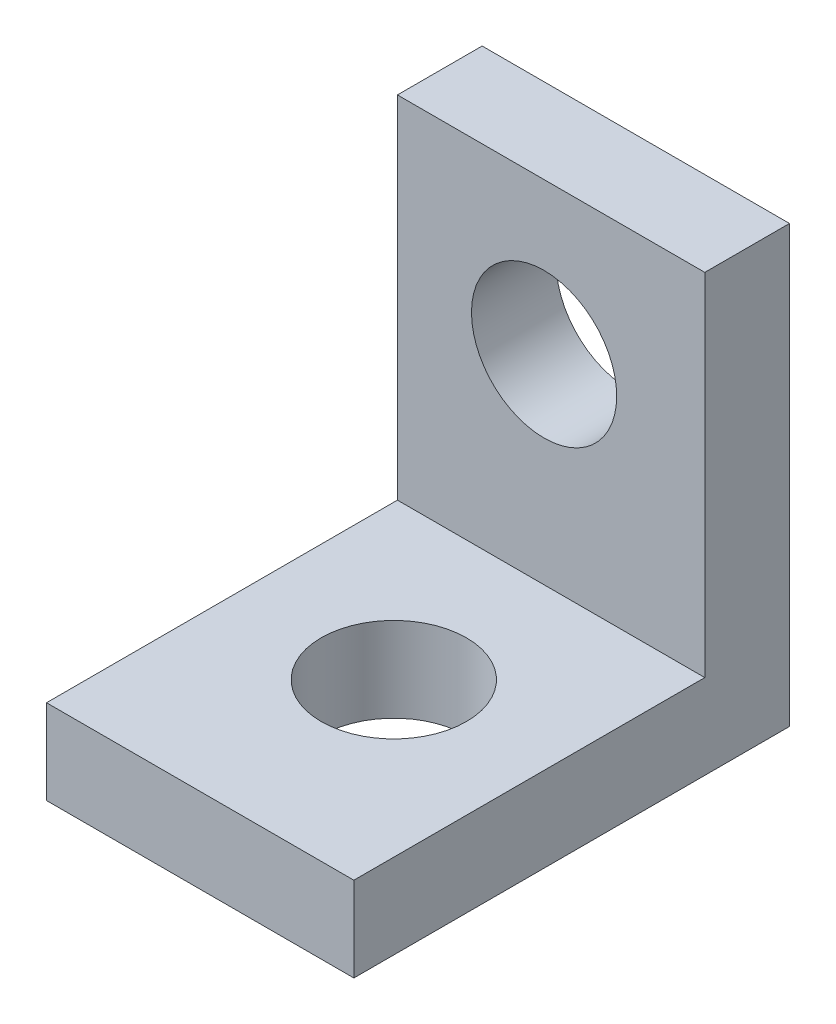
from build123d import *

# Parameters (mm, degrees)
SKETCH1_W               = 6.35
SKETCH1_H               = 9
SKETCH1_R               = 1.5
BOSS_EXTRUDE1_DEPTH     = 1.75
SKETCH2_W               = 6.35
SKETCH2_H               = 1.75
BOSS_EXTRUDE2_DEPTH     = 7.25
SKETCH3_R               = 1.5
CUT_EXTRUDE1_DEPTH      = 8.25
CUT_EXTRUDE1_DEPTH_BACK = 2.75


with BuildPart() as part:
    # Sketch1 → Boss-Extrude1 (new body)
    with BuildSketch(Plane(origin=(0, 0, 0), x_dir=(1, 0, 0), z_dir=(0, 1, 0))):
        with Locations((2.570238095, -2.458928571)):
            Rectangle(SKETCH1_W, SKETCH1_H)
        with Locations((2.570238095, -2.958928571)):
            Circle(SKETCH1_R, mode=Mode.SUBTRACT)
    extrude(amount=BOSS_EXTRUDE1_DEPTH)

    # Sketch2 → Boss-Extrude2 (add)
    with BuildSketch(Plane(origin=(0, 1.75, 0), x_dir=(1, 0, 0), z_dir=(0, 1, 0))):
        with Locations((2.570238095, 1.166071429)):
            Rectangle(SKETCH2_W, SKETCH2_H)
    extrude(amount=BOSS_EXTRUDE2_DEPTH)

    # Sketch3 → Cut-Extrude1 (cut, two sides)
    with BuildSketch(Plane.XY.offset(-0.291071429)) as cut_extrude1_sk:
        with Locations((2.425238095, 5.875)):
            Circle(SKETCH3_R)
    extrude(amount=CUT_EXTRUDE1_DEPTH, mode=Mode.SUBTRACT)
    extrude(cut_extrude1_sk.sketch, amount=-CUT_EXTRUDE1_DEPTH_BACK, mode=Mode.SUBTRACT)


solid = part.part
